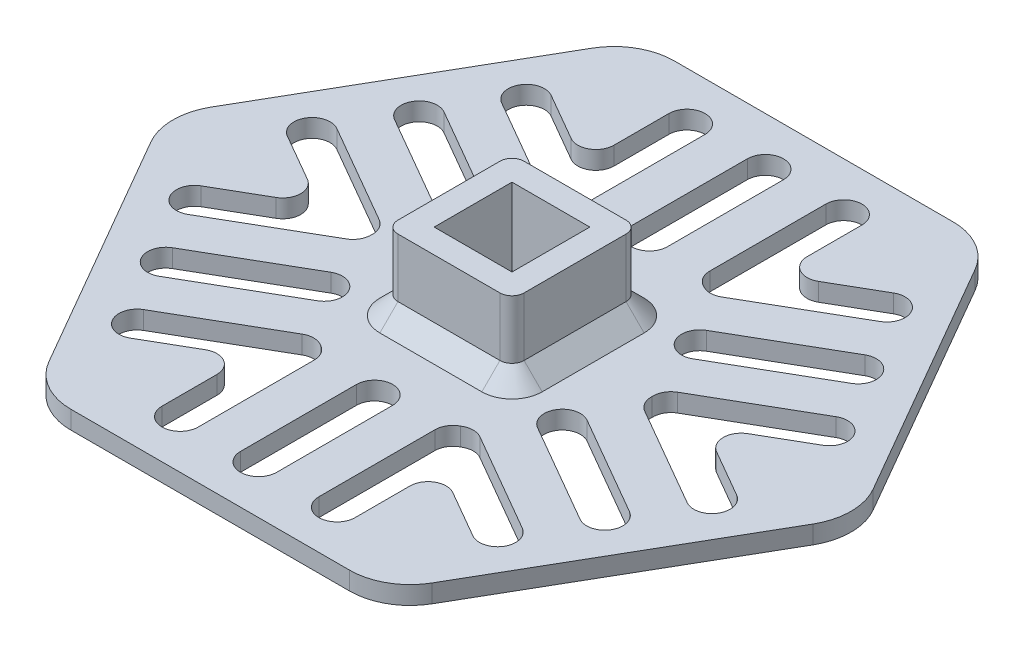
from build123d import *

# Parameters (mm, degrees)
SKETCH1_W                 = 20.9
SKETCH1_H                 = 20.9
SKETCH1_W_2               = 12.9
SKETCH1_H_2               = 12.9
BOSS_EXTRUDE1_DEPTH       = 12.7
BOSS_EXTRUDE2_DEPTH       = 3
CUT_EXTRUDE1_DEPTH        = 4
LPATTERN1_COUNT           = 2
LPATTERN1_PITCH           = 13
LPATTERN1_COL_COUNT       = 2
LPATTERN1_COL_PITCH       = 13
CIRPATTERN1_COUNT         = 6
CIRPATTERN1_COPY_1_DEPTH  = 4
CIRPATTERN1_COPY_2_DEPTH  = 4
CIRPATTERN1_COPY_3_DEPTH  = 4
CIRPATTERN1_COPY_4_DEPTH  = 4
CIRPATTERN1_COPY_5_DEPTH  = 4
CIRPATTERN1_COPY_6_DEPTH  = 4
CIRPATTERN1_COPY_7_DEPTH  = 4
CIRPATTERN1_COPY_8_DEPTH  = 4
CIRPATTERN1_COPY_9_DEPTH  = 4
CIRPATTERN1_COPY_10_DEPTH = 4
FILLET1_R                 = 3
FILLET2_R                 = 10
FILLET3_R                 = 2
CHAMFER1_SIZE             = 3


with BuildPart() as part:
    # Sketch1 → Boss-Extrude1 (new body)
    with BuildSketch(Plane(origin=(0, 0, 0), x_dir=(1, 0, 0), z_dir=(0, 1, 0))):
        Rectangle(SKETCH1_W, SKETCH1_H)
        Rectangle(SKETCH1_W_2, SKETCH1_H_2, mode=Mode.SUBTRACT)
    extrude(amount=-BOSS_EXTRUDE1_DEPTH)

    # Sketch2 → Boss-Extrude2 (add)
    with BuildSketch(Plane.XZ.offset(12.7)):
        Polygon((57.735026919, 0), (28.867513459, 50), (-28.867513459, 50), (-57.735026919, 0), (-28.867513459, -50), (28.867513459, -50), align=None)
    extrude(amount=BOSS_EXTRUDE2_DEPTH)

    # Sketch3 → Cut-Extrude1 (cut, through all)
    with BuildSketch(Plane(origin=(0, -12.7, 0), x_dir=(1, 0, 0), z_dir=(0, 1, 0))):
        with BuildLine():
            Line((-34.873066959, 23.598076211), (-18.226787136, 13.987342075))
            ThreePointArc((-18.226787136, 13.987342075), (-17.128710925, 9.889265863), (-21.226787136, 8.791189652))
            Line((-21.226787136, 8.791189652), (-37.873066959, 18.401923789))
            ThreePointArc((-37.873066959, 18.401923789), (-38.97114317, 22.5), (-34.873066959, 23.598076211))
        make_face()
    cut_extrude1 = extrude(amount=-CUT_EXTRUDE1_DEPTH, mode=Mode.SUBTRACT)

    # LPattern1: Cut-Extrude1 ×2
    with Locations(*[Vector(-0.5, 0, 0.866025404) * (i * LPATTERN1_PITCH) for i in range(1, LPATTERN1_COUNT)]):
        add(cut_extrude1, mode=Mode.SUBTRACT)

    # LPattern1 col: Cut-Extrude1 ×2
    with Locations(*[Vector(0.5, 0, -0.866025404) * (i * LPATTERN1_COL_PITCH) for i in range(1, LPATTERN1_COL_COUNT)]):
        add(cut_extrude1, mode=Mode.SUBTRACT)

    # CirPattern1: Cut-Extrude1 ×6 about axis
    cirpattern1_axis = Axis((0, 0, 0), (0, 1, 0))
    for i in range(1, CIRPATTERN1_COUNT):
        add(cut_extrude1.rotate(cirpattern1_axis, i * 360 / CIRPATTERN1_COUNT), mode=Mode.SUBTRACT)

    # CirPattern1 copy 1 sketch → CirPattern1 copy 1 (cut, through all)
    with BuildSketch(Plane(origin=(6.5, -12.7, 11.258330249), x_dir=(0.5, 0, -0.866025404), z_dir=(0, 1, 0))):
        with BuildLine():
            Line((-34.873066959, 23.598076211), (-18.226787136, 13.987342075))
            ThreePointArc((-18.226787136, 13.987342075), (-17.128710925, 9.889265863), (-21.226787136, 8.791189652))
            Line((-21.226787136, 8.791189652), (-37.873066959, 18.401923789))
            ThreePointArc((-37.873066959, 18.401923789), (-38.97114317, 22.5), (-34.873066959, 23.598076211))
        make_face()
    extrude(amount=-CIRPATTERN1_COPY_1_DEPTH, mode=Mode.SUBTRACT)

    # CirPattern1 copy 2 sketch → CirPattern1 copy 2 (cut, through all)
    with BuildSketch(Plane(origin=(13, -12.7, 0), x_dir=(-0.5, 0, -0.866025404), z_dir=(0, 1, 0))):
        with BuildLine():
            Line((-34.873066959, 23.598076211), (-18.226787136, 13.987342075))
            ThreePointArc((-18.226787136, 13.987342075), (-17.128710925, 9.889265863), (-21.226787136, 8.791189652))
            Line((-21.226787136, 8.791189652), (-37.873066959, 18.401923789))
            ThreePointArc((-37.873066959, 18.401923789), (-38.97114317, 22.5), (-34.873066959, 23.598076211))
        make_face()
    extrude(amount=-CIRPATTERN1_COPY_2_DEPTH, mode=Mode.SUBTRACT)

    # CirPattern1 copy 3 sketch → CirPattern1 copy 3 (cut, through all)
    with BuildSketch(Plane(origin=(6.5, -12.7, -11.258330249), x_dir=(-1, 0, 0), z_dir=(0, 1, 0))):
        with BuildLine():
            Line((-34.873066959, 23.598076211), (-18.226787136, 13.987342075))
            ThreePointArc((-18.226787136, 13.987342075), (-17.128710925, 9.889265863), (-21.226787136, 8.791189652))
            Line((-21.226787136, 8.791189652), (-37.873066959, 18.401923789))
            ThreePointArc((-37.873066959, 18.401923789), (-38.97114317, 22.5), (-34.873066959, 23.598076211))
        make_face()
    extrude(amount=-CIRPATTERN1_COPY_3_DEPTH, mode=Mode.SUBTRACT)

    # CirPattern1 copy 4 sketch → CirPattern1 copy 4 (cut, through all)
    with BuildSketch(Plane(origin=(-6.5, -12.7, -11.258330249), x_dir=(-0.5, 0, 0.866025404), z_dir=(0, 1, 0))):
        with BuildLine():
            Line((-34.873066959, 23.598076211), (-18.226787136, 13.987342075))
            ThreePointArc((-18.226787136, 13.987342075), (-17.128710925, 9.889265863), (-21.226787136, 8.791189652))
            Line((-21.226787136, 8.791189652), (-37.873066959, 18.401923789))
            ThreePointArc((-37.873066959, 18.401923789), (-38.97114317, 22.5), (-34.873066959, 23.598076211))
        make_face()
    extrude(amount=-CIRPATTERN1_COPY_4_DEPTH, mode=Mode.SUBTRACT)

    # CirPattern1 copy 5 sketch → CirPattern1 copy 5 (cut, through all)
    with BuildSketch(Plane(origin=(-13, -12.7, 0), x_dir=(0.5, 0, 0.866025404), z_dir=(0, 1, 0))):
        with BuildLine():
            Line((-34.873066959, 23.598076211), (-18.226787136, 13.987342075))
            ThreePointArc((-18.226787136, 13.987342075), (-17.128710925, 9.889265863), (-21.226787136, 8.791189652))
            Line((-21.226787136, 8.791189652), (-37.873066959, 18.401923789))
            ThreePointArc((-37.873066959, 18.401923789), (-38.97114317, 22.5), (-34.873066959, 23.598076211))
        make_face()
    extrude(amount=-CIRPATTERN1_COPY_5_DEPTH, mode=Mode.SUBTRACT)

    # CirPattern1 copy 6 sketch → CirPattern1 copy 6 (cut, through all)
    with BuildSketch(Plane(origin=(-6.5, -12.7, -11.258330249), x_dir=(0.5, 0, -0.866025404), z_dir=(0, 1, 0))):
        with BuildLine():
            Line((-34.873066959, 23.598076211), (-18.226787136, 13.987342075))
            ThreePointArc((-18.226787136, 13.987342075), (-17.128710925, 9.889265863), (-21.226787136, 8.791189652))
            Line((-21.226787136, 8.791189652), (-37.873066959, 18.401923789))
            ThreePointArc((-37.873066959, 18.401923789), (-38.97114317, 22.5), (-34.873066959, 23.598076211))
        make_face()
    extrude(amount=-CIRPATTERN1_COPY_6_DEPTH, mode=Mode.SUBTRACT)

    # CirPattern1 copy 7 sketch → CirPattern1 copy 7 (cut, through all)
    with BuildSketch(Plane(origin=(-13, -12.7, 0), x_dir=(-0.5, 0, -0.866025404), z_dir=(0, 1, 0))):
        with BuildLine():
            Line((-34.873066959, 23.598076211), (-18.226787136, 13.987342075))
            ThreePointArc((-18.226787136, 13.987342075), (-17.128710925, 9.889265863), (-21.226787136, 8.791189652))
            Line((-21.226787136, 8.791189652), (-37.873066959, 18.401923789))
            ThreePointArc((-37.873066959, 18.401923789), (-38.97114317, 22.5), (-34.873066959, 23.598076211))
        make_face()
    extrude(amount=-CIRPATTERN1_COPY_7_DEPTH, mode=Mode.SUBTRACT)

    # CirPattern1 copy 8 sketch → CirPattern1 copy 8 (cut, through all)
    with BuildSketch(Plane(origin=(-6.5, -12.7, 11.258330249), x_dir=(-1, 0, 0), z_dir=(0, 1, 0))):
        with BuildLine():
            Line((-34.873066959, 23.598076211), (-18.226787136, 13.987342075))
            ThreePointArc((-18.226787136, 13.987342075), (-17.128710925, 9.889265863), (-21.226787136, 8.791189652))
            Line((-21.226787136, 8.791189652), (-37.873066959, 18.401923789))
            ThreePointArc((-37.873066959, 18.401923789), (-38.97114317, 22.5), (-34.873066959, 23.598076211))
        make_face()
    extrude(amount=-CIRPATTERN1_COPY_8_DEPTH, mode=Mode.SUBTRACT)

    # CirPattern1 copy 9 sketch → CirPattern1 copy 9 (cut, through all)
    with BuildSketch(Plane(origin=(6.5, -12.7, 11.258330249), x_dir=(-0.5, 0, 0.866025404), z_dir=(0, 1, 0))):
        with BuildLine():
            Line((-34.873066959, 23.598076211), (-18.226787136, 13.987342075))
            ThreePointArc((-18.226787136, 13.987342075), (-17.128710925, 9.889265863), (-21.226787136, 8.791189652))
            Line((-21.226787136, 8.791189652), (-37.873066959, 18.401923789))
            ThreePointArc((-37.873066959, 18.401923789), (-38.97114317, 22.5), (-34.873066959, 23.598076211))
        make_face()
    extrude(amount=-CIRPATTERN1_COPY_9_DEPTH, mode=Mode.SUBTRACT)

    # CirPattern1 copy 10 sketch → CirPattern1 copy 10 (cut, through all)
    with BuildSketch(Plane(origin=(13, -12.7, 0), x_dir=(0.5, 0, 0.866025404), z_dir=(0, 1, 0))):
        with BuildLine():
            Line((-34.873066959, 23.598076211), (-18.226787136, 13.987342075))
            ThreePointArc((-18.226787136, 13.987342075), (-17.128710925, 9.889265863), (-21.226787136, 8.791189652))
            Line((-21.226787136, 8.791189652), (-37.873066959, 18.401923789))
            ThreePointArc((-37.873066959, 18.401923789), (-38.97114317, 22.5), (-34.873066959, 23.598076211))
        make_face()
    extrude(amount=-CIRPATTERN1_COPY_10_DEPTH, mode=Mode.SUBTRACT)

    # Fillet1
    fillet1_edges = [part.edges().sort_by_distance(p)[0] for p in [
        (-16, -14.2, -27.712812921),
        (-16, -14.2, 27.712812921),
        (16, -14.2, 27.712812921),
        (32, -14.2, 0),
        (16, -14.2, -27.712812921),
        (-32, -14.2, 0),
    ]]
    fillet(fillet1_edges, radius=FILLET1_R)

    # Fillet2
    fillet2_edges = [part.edges().sort_by_distance(p)[0] for p in [
        (28.867513459, -14.2, -50),
        (57.735026919, -14.2, 0),
        (28.867513459, -14.2, 50),
        (-28.867513459, -14.2, 50),
        (-57.735026919, -14.2, 0),
        (-28.867513459, -14.2, -50),
    ]]
    fillet(fillet2_edges, radius=FILLET2_R)

    # Fillet3
    fillet3_edges = [part.edges().sort_by_distance(p)[0] for p in [
        (-10.45, -6.35, -10.45),
        (10.45, -6.35, -10.45),
        (10.45, -6.35, 10.45),
        (-10.45, -6.35, 10.45),
    ]]
    fillet(fillet3_edges, radius=FILLET3_R)

    # Chamfer1
    chamfer1_edges = [part.edges().sort_by_distance(p)[0] for p in [
        (-10.45, -12.7, 0),
        (0, -12.7, 10.45),
        (10.45, -12.7, 0),
        (0, -12.7, -10.45),
        (-9.864213562, -12.7, 9.864213562),
        (9.864213562, -12.7, 9.864213562),
        (9.864213562, -12.7, -9.864213562),
        (-9.864213562, -12.7, -9.864213562),
    ]]
    chamfer(chamfer1_edges, length=CHAMFER1_SIZE)


solid = part.part
